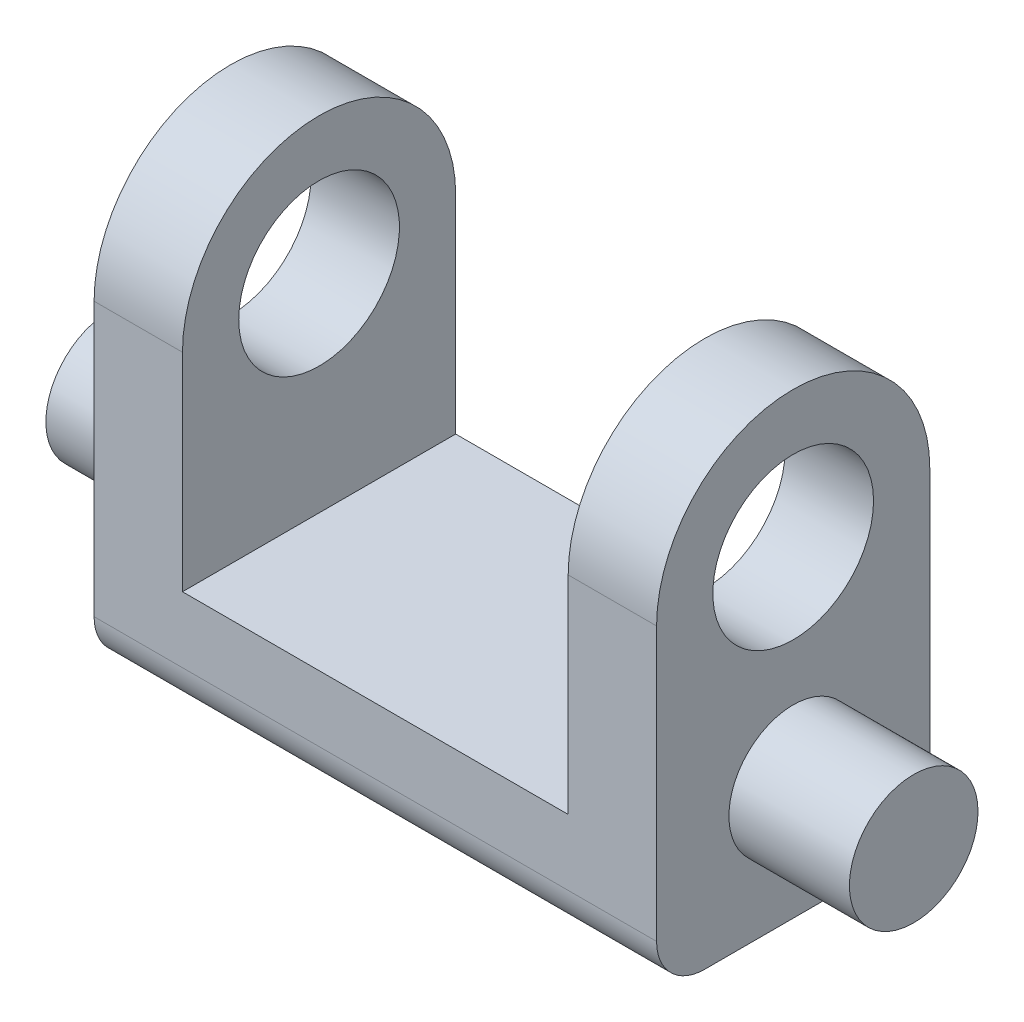
from build123d import *

# Parameters (mm, degrees)
SKETCH1_R           = 8
BOSS_EXTRUDE1_DEPTH = 50
SKETCH2_R           = 10
BOSS_EXTRUDE2_DEPTH = 35
SKETCH5_W           = 48
SKETCH5_H           = 42.813252044
CUT_EXTRUDE1_DEPTH  = 74.620649277


with BuildPart() as part:
    # Sketch1 → Boss-Extrude1 (new, symmetric)
    with BuildSketch(Plane(origin=(0, 0, 0), x_dir=(0, 0, -1), z_dir=(1, 0, 0))):
        Circle(SKETCH1_R)
    extrude(amount=BOSS_EXTRUDE1_DEPTH, both=True)

    # Sketch2 → Boss-Extrude2 (add, symmetric)
    with BuildSketch(Plane(origin=(0, 0, 0), x_dir=(0, 0, -1), z_dir=(1, 0, 0))):
        with BuildLine():
            Line((-11, -15), (11, -15))
            ThreePointArc((11, -15), (15.242640687, -13.242640687), (17, -9))
            Line((17, -9), (17, 25))
            ThreePointArc((17, 25), (0, 42), (-17, 25))
            Line((-17, 25), (-17, -9))
            ThreePointArc((-17, -9), (-15.242640687, -13.242640687), (-11, -15))
        make_face()
        with Locations((0, 25)):
            Circle(SKETCH2_R, mode=Mode.SUBTRACT)
    extrude(amount=BOSS_EXTRUDE2_DEPTH, both=True)

    # Sketch5 → Cut-Extrude1 (cut, through all)
    with BuildSketch(Plane.XY.offset(17)):
        with Locations((0, 20.593373978)):
            Rectangle(SKETCH5_W, SKETCH5_H)
    extrude(amount=-CUT_EXTRUDE1_DEPTH, mode=Mode.SUBTRACT)


solid = part.part
